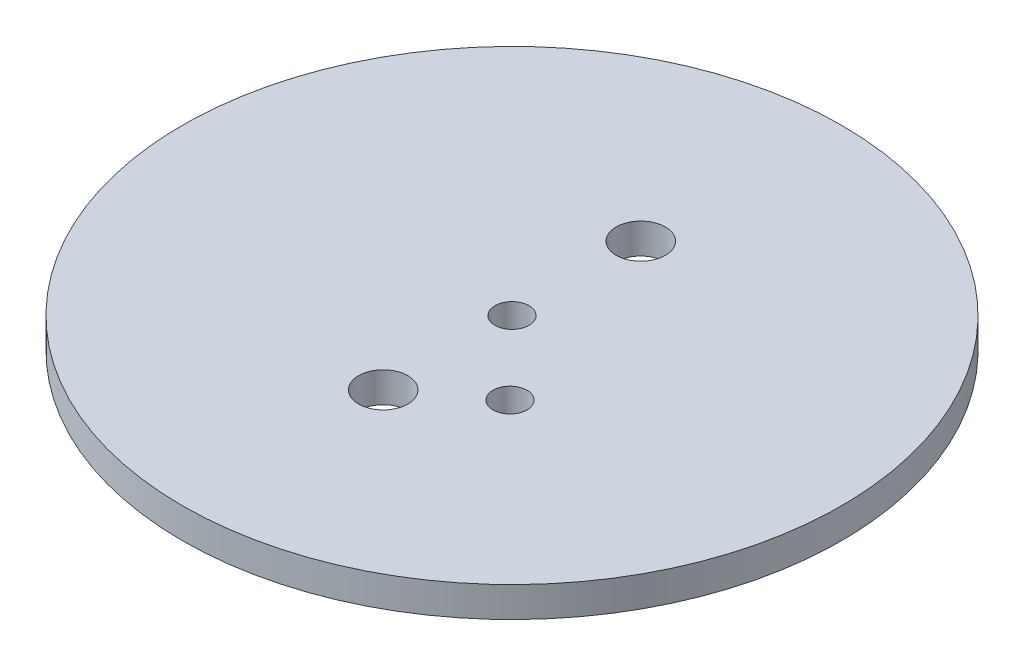
from build123d import *

# Parameters (mm, degrees)
SKETCH1_R               = 69.05625
BOSS_EXTRUDE1_DEPTH     = 6.35
F_1_4_CLEARANCE_HOLE1_D = 7.14248
F_3_8_CLEARANCE_HOLE1_D = 10.31748
SKETCH6_R               = 3.57124
CUT_EXTRUDE1_DEPTH      = 6.35


with BuildPart() as part:
    # Sketch1 → Boss-Extrude1 (new body)
    with BuildSketch(Plane(origin=(0, 0, 0), x_dir=(1, 0, 0), z_dir=(0, 1, 0))):
        Circle(SKETCH1_R)
    extrude(amount=BOSS_EXTRUDE1_DEPTH)

    # 1/4 Clearance Hole1 (through all)
    with Locations(Plane(origin=(0, 6.35, 0), x_dir=(1, 0, 0), z_dir=(0, 1, 0))):
        with Locations((0, 0)):
            Hole(F_1_4_CLEARANCE_HOLE1_D / 2)

    # 3/8 Clearance Hole1 (through all)
    with Locations(Plane(origin=(0, 6.35, 0), x_dir=(1, 0, 0), z_dir=(0, 1, 0))):
        with Locations((0, 26.9875), (0, -26.9875)):
            Hole(F_3_8_CLEARANCE_HOLE1_D / 2)

    # Sketch6 → Cut-Extrude1 (cut)
    with BuildSketch(Plane(origin=(0, 6.35, 0), x_dir=(1, 0, 0), z_dir=(0, 1, 0))):
        with Locations((15.1384, -15.5575)):
            Circle(SKETCH6_R)
    extrude(amount=-CUT_EXTRUDE1_DEPTH, mode=Mode.SUBTRACT)


solid = part.part
